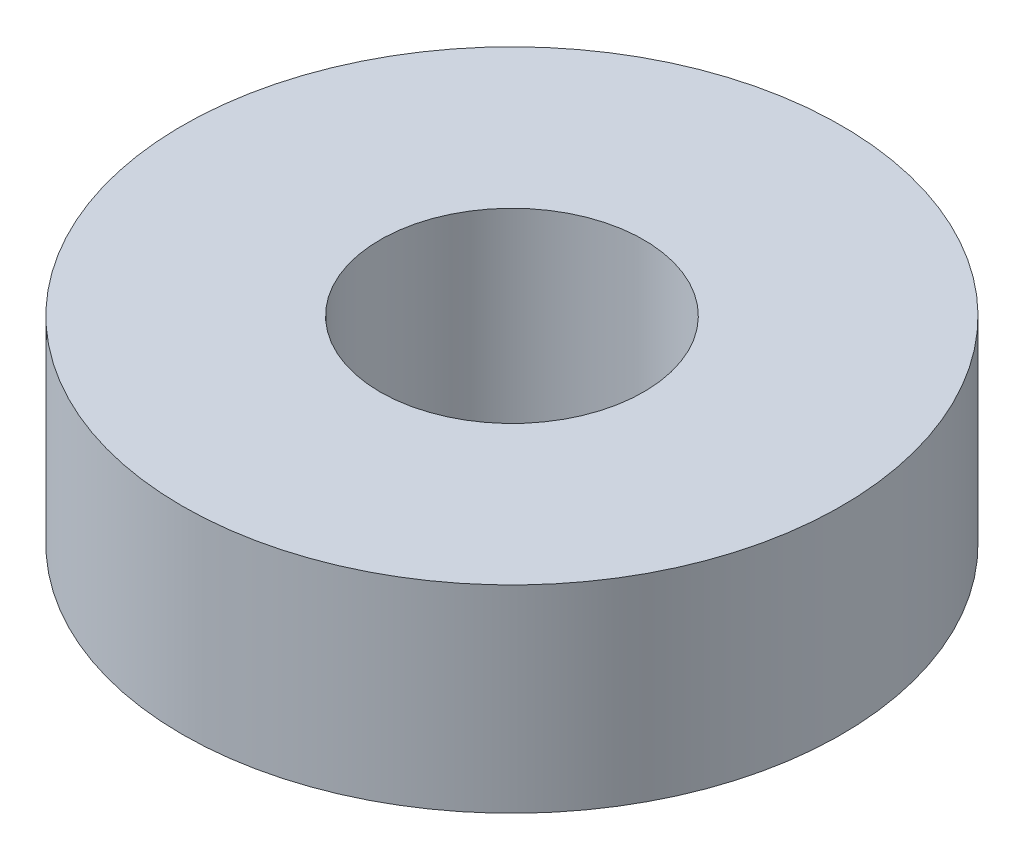
from build123d import *

# Parameters (mm, degrees)
SKETCH1_R           = 7.9375
BOSS_EXTRUDE1_DEPTH = 4.7625
SKETCH2_R           = 3.175
CUT_EXTRUDE1_DEPTH  = 5.7625


with BuildPart() as part:
    # Sketch1 → Boss-Extrude1 (new body)
    with BuildSketch(Plane(origin=(0, 0, 0), x_dir=(1, 0, 0), z_dir=(0, 1, 0))):
        Circle(SKETCH1_R)
    extrude(amount=BOSS_EXTRUDE1_DEPTH)

    # Sketch2 → Cut-Extrude1 (cut, through all)
    with BuildSketch(Plane(origin=(0, 4.7625, 0), x_dir=(1, 0, 0), z_dir=(0, 1, 0))):
        Circle(SKETCH2_R)
    extrude(amount=-CUT_EXTRUDE1_DEPTH, mode=Mode.SUBTRACT)


solid = part.part
